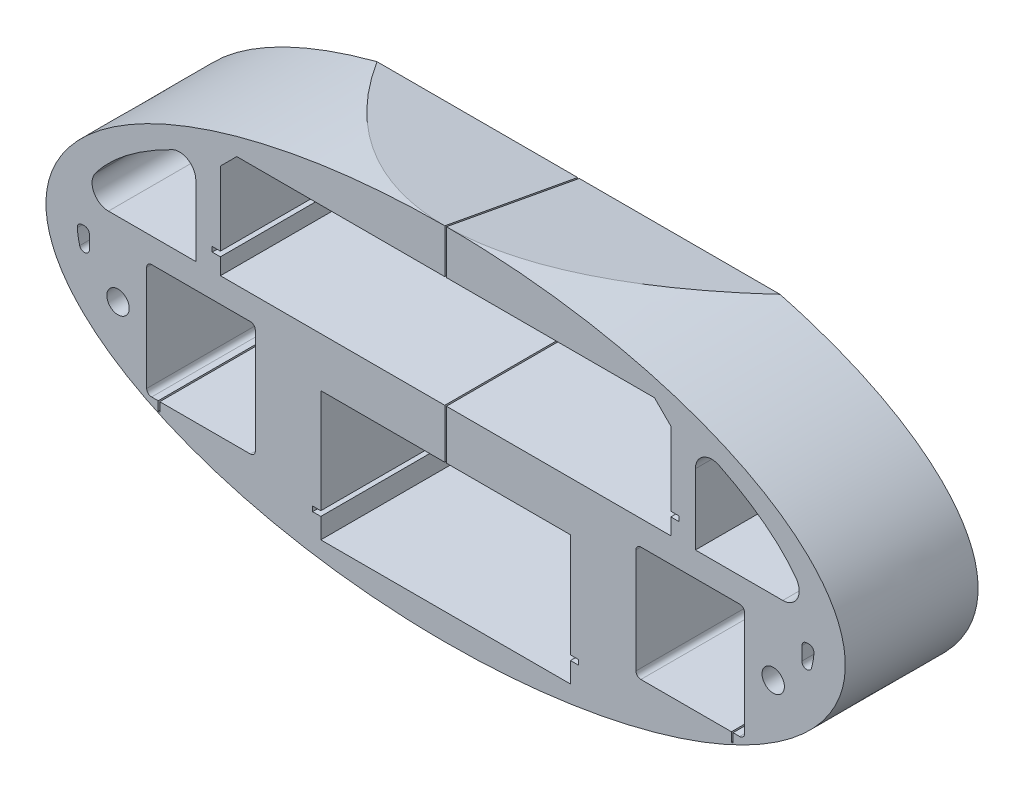
from build123d import *

# Parameters (mm, degrees)
SKETCH1_RX               = 244
SKETCH1_RY               = 110
BOSS_EXTRUDE1_DEPTH      = 81.0825
CUT_EXTRUDE5_DEPTH       = 82.0825
SKETCH12_R               = 6.83635542
CUT_EXTRUDE8_DEPTH       = 82.0825
CUT_EXTRUDE9_DEPTH       = 245
CUT_EXTRUDE9_DEPTH_BACK  = 245
CUT_EXTRUDE14_DEPTH      = 1.000000698
CUT_EXTRUDE14_DEPTH_BACK = 82.0825001
SKETCH15_W               = 66.3
SKETCH15_H               = 70
CUT_EXTRUDE16_DEPTH      = 1.000000698
CUT_EXTRUDE16_DEPTH_BACK = 82.0825001
SKETCH16_W               = 1
SKETCH16_H               = 45.520413792
SKETCH16_H_2             = 125
CUT_EXTRUDE17_DEPTH      = 1.000000698
CUT_EXTRUDE17_DEPTH_BACK = 82.0825001
FILLET1_R                = 10
FILLET3_R                = 3
CHAMFER1_SIZE            = 10


with BuildPart() as part:
    # Sketch1 → Boss-Extrude1 (new body)
    with BuildSketch(Plane.XY):
        with Locations((0, 0)):
            Ellipse(SKETCH1_RX, SKETCH1_RY)
    extrude(amount=-BOSS_EXTRUDE1_DEPTH)

    # Sketch10 → Cut-Extrude5 (cut, through all)
    with BuildSketch(Plane.XY):
        Polygon((-137.5, 83.1), (137.5, 83.1), (137.5, 28.1), (142.5, 28.1), (142.5, 25.1), (137.5, 25.1), (137.5, 15.1), (-137.5, 15.1), (-137.5, 25.1), (-142.5, 25.1), (-142.5, 28.1), (-137.5, 28.1), align=None)
    extrude(amount=-CUT_EXTRUDE5_DEPTH, mode=Mode.SUBTRACT)

    # Sketch12 → Cut-Extrude8 (cut, through all)
    with BuildSketch(Plane.XY):
        with Locations((200, -30)):
            Circle(SKETCH12_R)
        with Locations((-200, -30)):
            Circle(SKETCH12_R)
    extrude(amount=-CUT_EXTRUDE8_DEPTH, mode=Mode.SUBTRACT)

    # Sketch14 → Cut-Extrude9 (cut, two sides)
    with BuildSketch(Plane(origin=(0, 0, 0), x_dir=(0, 0, -1), z_dir=(1, 0, 0))) as cut_extrude9_sk:
        Polygon((0, 110), (81.0825, 95), (81.0825, 110), align=None)
        Polygon((0, -110), (81.0825, -105), (81.0825, -110), align=None)
    extrude(amount=CUT_EXTRUDE9_DEPTH, mode=Mode.SUBTRACT)
    extrude(cut_extrude9_sk.sketch, amount=-CUT_EXTRUDE9_DEPTH_BACK, mode=Mode.SUBTRACT)

    # Sketch21 → Cut-Extrude14 (cut, two sides)
    with BuildSketch(Plane.XY) as cut_extrude14_sk:
        Polygon((76.2, -81.5), (76.2, -93.9), (-76.2, -93.9), (-76.2, -81.5), (-81.2, -81.5), (-81.2, -78.5), (-76.2, -78.5), (-76.2, -15), (76.2, -15), (76.2, -78.5), (81.2, -78.5), (81.2, -81.5), align=None)
    extrude(amount=CUT_EXTRUDE14_DEPTH, mode=Mode.SUBTRACT)
    extrude(cut_extrude14_sk.sketch, amount=-CUT_EXTRUDE14_DEPTH_BACK, mode=Mode.SUBTRACT)

    # Sketch15 → Cut-Extrude16 (cut, two sides)
    with BuildSketch(Plane.XY) as cut_extrude16_sk:
        with BuildLine():
            Line((152.5, 73.52668114), (152.5, 15.1))
            Line((152.5, 15.1), (222.420096608, 15.1))
            add(Edge.make_bspline(
                [(222.420096608, 15.1), (210.507279325, 49.76143368), (152.5, 73.52668114)],
                knots=[0.151579794, 0.151579794, 0.151579794, 0.826060253, 0.826060253, 0.826060253], degree=2, weights=[1, 0.943671422, 1]))
        make_face()
        with BuildLine():
            Line((-217.5, -25.60381916), (-217.5, 0))
            Line((-217.5, 0), (-225, 0))
            add(Edge.make_bspline(
                [(-225, 0), (-225, -13.018891098), (-217.5, -25.60381916)],
                knots=[3.141592654, 3.141592654, 3.141592654, 3.400514196, 3.400514196, 3.400514196], degree=2, weights=[1, 0.991631652, 1]))
        make_face()
        with BuildLine():
            Line((217.5, -25.60381916), (217.5, 0))
            Line((217.5, 0), (225, 0))
            add(Edge.make_bspline(
                [(217.5, -25.60381916), (225, -13.018891098), (225, 0)],
                knots=[6.024263765, 6.024263765, 6.024263765, 6.283185307, 6.283185307, 6.283185307], degree=2, weights=[1, 0.991631652, 1]))
        make_face()
        with BuildLine():
            Line((-152.5, 15.1), (-222.420096608, 15.1))
            add(Edge.make_bspline(
                [(-152.5, 73.52668114), (-210.507279325, 49.76143368), (-222.420096608, 15.1)],
                knots=[2.3155324, 2.3155324, 2.3155324, 2.99001286, 2.99001286, 2.99001286], degree=2, weights=[1, 0.943671422, 1]))
            Line((-152.5, 73.52668114), (-152.5, 15.1))
        make_face()
        with Locations((149.35, -35)):
            Rectangle(SKETCH15_W, SKETCH15_H)
        with Locations((-149.35, -35)):
            Rectangle(SKETCH15_W, SKETCH15_H)
    extrude(amount=CUT_EXTRUDE16_DEPTH, mode=Mode.SUBTRACT)
    extrude(cut_extrude16_sk.sketch, amount=-CUT_EXTRUDE16_DEPTH_BACK, mode=Mode.SUBTRACT)

    # Sketch16 → Cut-Extrude17 (cut, two sides)
    with BuildSketch(Plane.XY) as cut_extrude17_sk:
        with Locations((175, -52.760206896)):
            Rectangle(SKETCH16_W, SKETCH16_H)
        with Locations((-175, -52.760206896)):
            Rectangle(SKETCH16_W, SKETCH16_H)
        with Locations((0, 47.5)):
            Rectangle(SKETCH16_W, SKETCH16_H_2)
    extrude(amount=CUT_EXTRUDE17_DEPTH, mode=Mode.SUBTRACT)
    extrude(cut_extrude17_sk.sketch, amount=-CUT_EXTRUDE17_DEPTH_BACK, mode=Mode.SUBTRACT)

    # Fillet1
    fillet1_edges = [part.edges().sort_by_distance(p)[0] for p in [
        (222.420096608, 15.1, -40.54125),
        (152.5, 73.52668114, -40.54125),
        (-222.420096608, 15.1, -40.54125),
        (-152.5, 73.52668114, -40.54125),
    ]]
    fillet(fillet1_edges, radius=FILLET1_R)

    # Fillet3
    fillet3_edges = [part.edges().sort_by_distance(p)[0] for p in [
        (217.5, 0, -40.54125),
        (-217.5, -25.60381916, -40.54125),
        (-225, 0, -40.54125),
        (-217.5, 0, -40.54125),
        (217.5, -25.60381916, -40.54125),
        (225, 0, -40.54125),
        (116.2, -70, -40.54125),
        (-182.5, -70, -40.54125),
        (-116.2, -70, -40.54125),
        (182.5, -70, -40.54125),
        (182.5, 0, -40.54125),
        (-116.2, 0, -40.54125),
        (116.2, 0, -40.54125),
        (-182.5, 0, -40.54125),
    ]]
    fillet(fillet3_edges, radius=FILLET3_R)

    # Chamfer1
    chamfer1_edges = [part.edges().sort_by_distance(p)[0] for p in [
        (-137.5, 83.1, -40.54125),
        (137.5, 83.1, -40.54125),
    ]]
    chamfer(chamfer1_edges, length=CHAMFER1_SIZE)


solid = part.part
